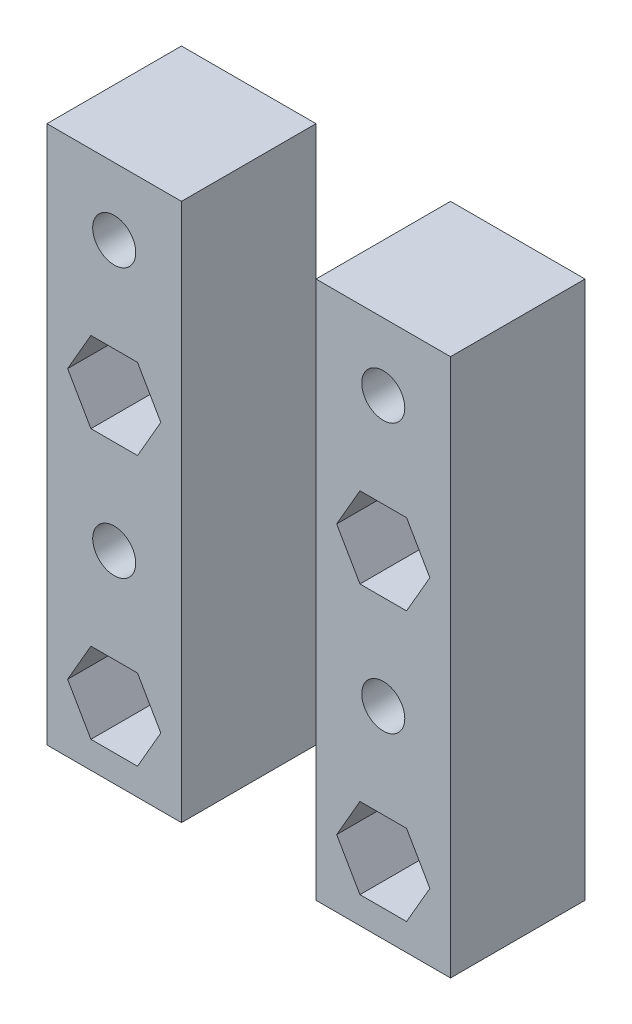
from build123d import *

# Parameters (mm, degrees)
SKETCH1_W           = 10
SKETCH1_H           = 30
SKETCH1_R           = 1.6
SKETCH1_H_2         = 10
BOSS_EXTRUDE1_DEPTH = 10
SKETCH4_R           = 1.6
CUT_EXTRUDE1_DEPTH  = 5


with BuildPart() as part:
    # Sketch1 → Boss-Extrude1 (new body)
    with BuildSketch(Plane.XY):
        with Locations((5, 15)):
            Rectangle(SKETCH1_W, SKETCH1_H)
        with Locations((5, 5)):
            Circle(SKETCH1_R, mode=Mode.SUBTRACT)
        with Locations((5, 15)):
            Circle(SKETCH1_R, mode=Mode.SUBTRACT)
        with Locations((5, 25)):
            Circle(SKETCH1_R, mode=Mode.SUBTRACT)
        with Locations((5, -5)):
            Rectangle(SKETCH1_W, SKETCH1_H_2)
        with Locations((5, -5)):
            Circle(SKETCH1_R, mode=Mode.SUBTRACT)
        with Locations((25, 15)):
            Rectangle(SKETCH1_W, SKETCH1_H)
        with Locations((25, 5)):
            Circle(SKETCH1_R, mode=Mode.SUBTRACT)
        with Locations((25, 15)):
            Circle(SKETCH1_R, mode=Mode.SUBTRACT)
        with Locations((25, 25)):
            Circle(SKETCH1_R, mode=Mode.SUBTRACT)
        with Locations((25, -5)):
            Rectangle(SKETCH1_W, SKETCH1_H_2)
        with Locations((25, -5)):
            Circle(SKETCH1_R, mode=Mode.SUBTRACT)
    extrude(amount=BOSS_EXTRUDE1_DEPTH)

    # Sketch4 → Cut-Extrude1 (cut)
    with BuildSketch(Plane.XY.offset(10)):
        Polygon((6.732050808, -8), (8.464101615, -5), (6.732050808, -2), (3.267949192, -2), (1.535898385, -5), (3.267949192, -8), align=None)
        Polygon((3.267949192, 12), (6.732050808, 12), (8.464101615, 15), (6.732050808, 18), (3.267949192, 18), (1.535898385, 15), align=None)
        Polygon((23.267949192, 12), (26.732050808, 12), (28.464101615, 15), (26.732050808, 18), (23.267949192, 18), (21.535898385, 15), align=None)
        with Locations((25, 15)):
            Circle(SKETCH4_R, mode=Mode.SUBTRACT)
        Polygon((23.267949192, -8), (26.732050808, -8), (28.464101615, -5), (26.732050808, -2), (23.267949192, -2), (21.535898385, -5), align=None)
        with Locations((25, -5)):
            Circle(SKETCH4_R, mode=Mode.SUBTRACT)
    extrude(amount=-CUT_EXTRUDE1_DEPTH, mode=Mode.SUBTRACT)


solid = part.part
